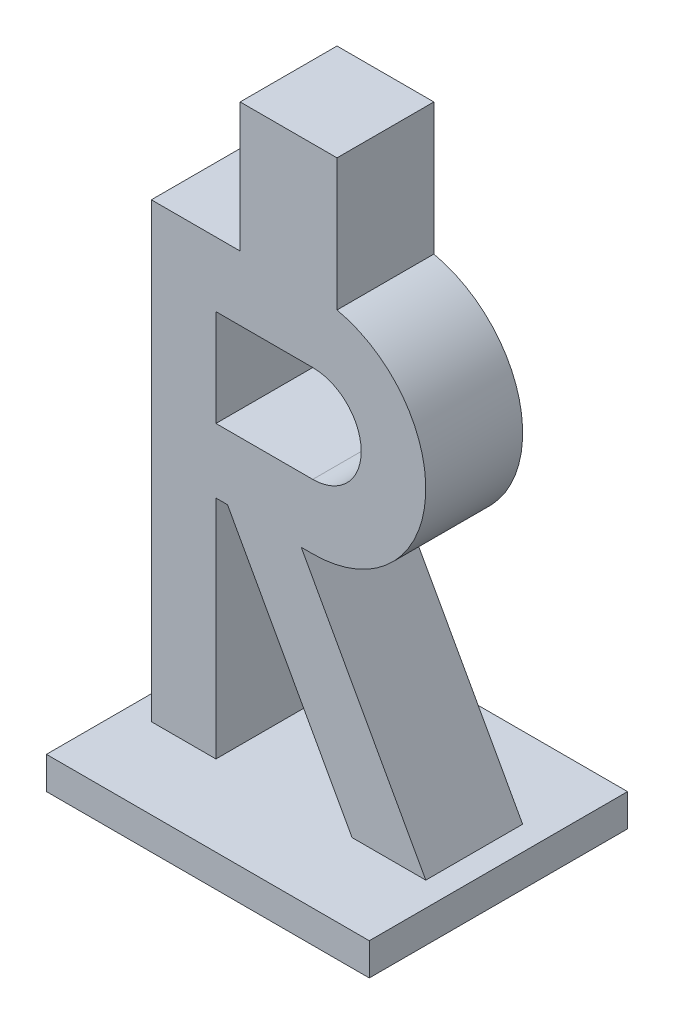
from build123d import *

# Parameters (mm, degrees)
AUFSATZ_LINEAR_AUSTRAGEN1_DEPTH = 15
SKIZZE2_W                       = 50
SKIZZE2_H                       = 40
AUFSATZ_LINEAR_AUSTRAGEN2_DEPTH = 5
SKIZZE6_W                       = 15
SKIZZE6_H                       = 20.406507086
AUFSATZ_LINEAR_AUSTRAGEN3_DEPTH = 15


with BuildPart() as part:
    # Skizze1 → Aufsatz-Linear austragen1 (new body)
    with BuildSketch(Plane.XY):
        with BuildLine():
            Line((0, 0), (0, 70))
            Line((0, 70), (25, 70))
            ThreePointArc((25, 70), (42.5, 52.5), (25, 35))
            Line((25, 35), (23.209169398, 35))
            Line((23.209169398, 35), (42.5, 0))
            Line((42.5, 0), (31.081661205, 0))
            Line((31.081661205, 0), (11.790830602, 35))
            Line((11.790830602, 35), (10, 35))
            Line((10, 35), (10, 0))
            Line((10, 0), (0, 0))
        make_face()
        with BuildLine():
            Line((10, 60), (10, 45))
            Line((10, 45), (25, 45))
            ThreePointArc((25, 45), (32.5, 52.5), (25, 60))
            Line((25, 60), (10, 60))
        make_face(mode=Mode.SUBTRACT)
    extrude(amount=AUFSATZ_LINEAR_AUSTRAGEN1_DEPTH)

    # Skizze2 → Aufsatz-Linear austragen2 (add)
    with BuildSketch(Plane.XZ):
        with Locations((21.25, 7.5)):
            Rectangle(SKIZZE2_W, SKIZZE2_H)
    extrude(amount=AUFSATZ_LINEAR_AUSTRAGEN2_DEPTH)

    # Skizze6 → Aufsatz-Linear austragen3 (add)
    with BuildSketch(Plane.XY.offset(15)):
        with Locations((21.25, 79.796746457)):
            Rectangle(SKIZZE6_W, SKIZZE6_H)
    extrude(amount=-AUFSATZ_LINEAR_AUSTRAGEN3_DEPTH)


solid = part.part
